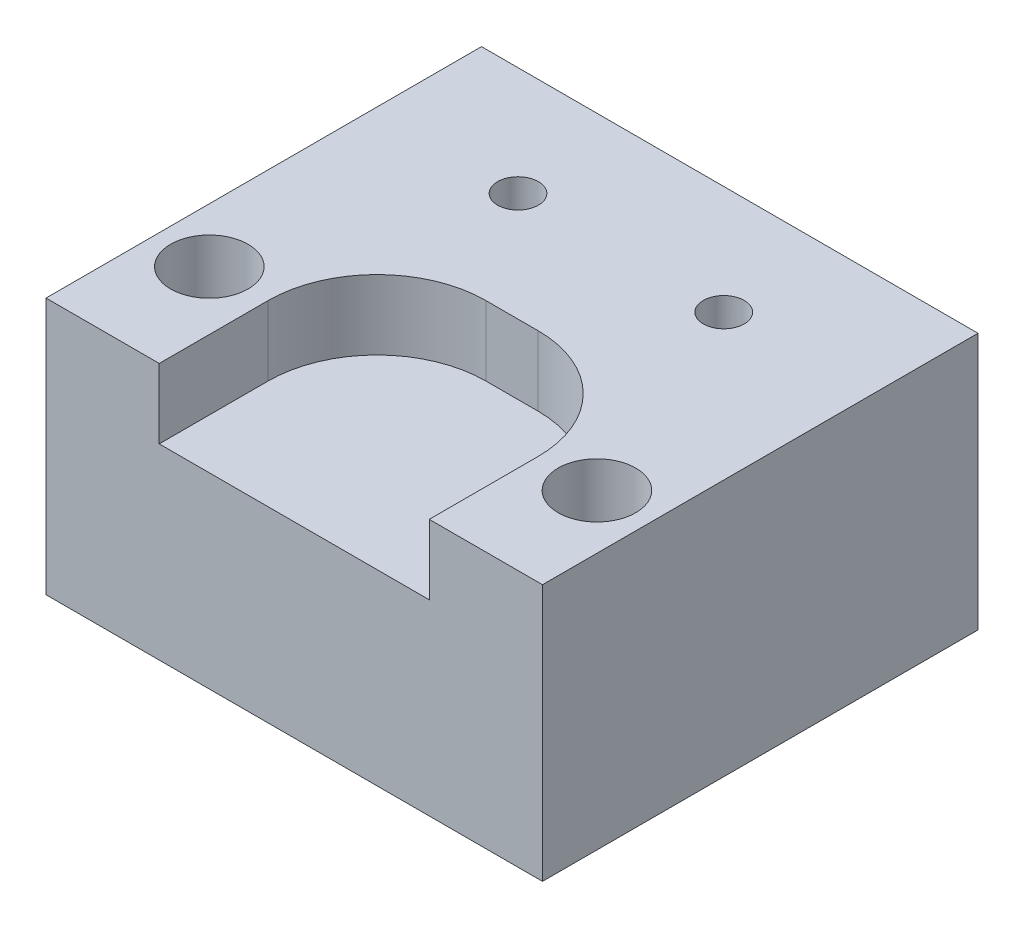
from build123d import *

# Parameters (mm, degrees)
SKETCH1_W                           = 14.478
SKETCH1_H                           = 12.7
BOSS_EXTRUDE1_DEPTH                 = 7.493
F_0_80_TAPPED_HOLE1_D               = 1.19126
F_2_CLEARANCE_HOLE1_D               = 2.2606
F_3_64_0_04688_DIAMETER_HOLE1_D     = 1.190752
F_3_64_0_04688_DIAMETER_HOLE1_DEPTH = 4.7625
F_3_64_0_04688_DIAMETER_HOLE1_TIP   = 0.357737992
SKETCH8_W                           = 7.874
SKETCH8_H                           = 12.7
CUT_EXTRUDE1_DEPTH                  = 2.032
FILLET1_R                           = 3.175


with BuildPart() as part:
    # Sketch1 → Boss-Extrude1 (new body)
    with BuildSketch(Plane(origin=(0, 0, 0), x_dir=(1, 0, 0), z_dir=(0, 1, 0))):
        Rectangle(SKETCH1_W, SKETCH1_H)
    extrude(amount=BOSS_EXTRUDE1_DEPTH)

    # #0-80 Tapped Hole1 (through all)
    with Locations(Plane(origin=(0, 7.493, 0), x_dir=(-1, 0, 0), z_dir=(0, 1, 0))):
        with Locations((3, -3.175), (-3, -3.175)):
            Hole(F_0_80_TAPPED_HOLE1_D / 2)

    # #2 Clearance Hole1 (through all)
    with Locations(Plane(origin=(0, 7.493, 0), x_dir=(-1, 0, 0), z_dir=(0, 1, 0))):
        with Locations((5.6515, 3.175), (-5.6515, 3.175)):
            Hole(F_2_CLEARANCE_HOLE1_D / 2)

    # 3/64 (0.04688) Diameter Hole1
    with Locations(Plane(origin=(0, 0, -6.35), x_dir=(-1, 0, 0), z_dir=(0, 0, -1))):
        with Locations((-2.9972, 3.7465), (2.9972, 3.7465)):
            Hole(F_3_64_0_04688_DIAMETER_HOLE1_D / 2, depth=F_3_64_0_04688_DIAMETER_HOLE1_DEPTH)
            with Locations((0, 0, -(F_3_64_0_04688_DIAMETER_HOLE1_DEPTH + F_3_64_0_04688_DIAMETER_HOLE1_TIP / 2))):  # 118° drill point
                Cone(0, F_3_64_0_04688_DIAMETER_HOLE1_D / 2, F_3_64_0_04688_DIAMETER_HOLE1_TIP, mode=Mode.SUBTRACT)

    # Sketch8 → Cut-Extrude1 (cut)
    with BuildSketch(Plane.XZ.offset(-7.493)):
        with Locations((0, 6.35)):
            Rectangle(SKETCH8_W, SKETCH8_H)
    extrude(amount=CUT_EXTRUDE1_DEPTH, mode=Mode.SUBTRACT)

    # Fillet1
    fillet1_edges = [part.edges().sort_by_distance(p)[0] for p in [
        (3.937, 6.477, 0),
        (-3.937, 6.477, 0),
    ]]
    fillet(fillet1_edges, radius=FILLET1_R)


solid = part.part
